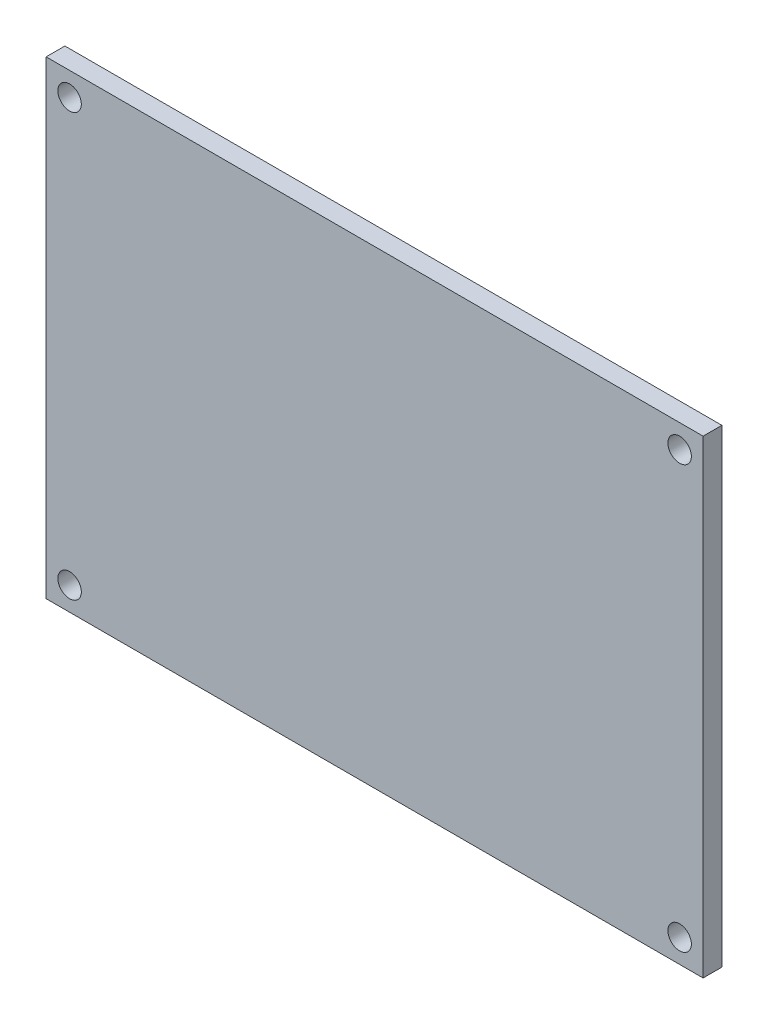
from build123d import *

# Parameters (mm, degrees)
SKETCH1_W           = 142
SKETCH1_H           = 102
SKETCH1_R           = 2.5
BOSS_EXTRUDE1_DEPTH = 4
SKETCH2_W           = 142
SKETCH2_H           = 102
SKETCH2_W_2         = 140
SKETCH2_H_2         = 100
CUT_EXTRUDE1_DEPTH  = 5


with BuildPart() as part:
    # Sketch1 → Boss-Extrude1 (new body)
    with BuildSketch(Plane.XY):
        with Locations((-27.181372549, -6.605392157)):
            Rectangle(SKETCH1_W, SKETCH1_H)
        with Locations((-92.181372549, 38.394607843)):
            Circle(SKETCH1_R, mode=Mode.SUBTRACT)
        with Locations((37.818627451, 38.394607843)):
            Circle(SKETCH1_R, mode=Mode.SUBTRACT)
        with Locations((37.818627451, -51.605392157)):
            Circle(SKETCH1_R, mode=Mode.SUBTRACT)
        with Locations((-92.181372549, -51.605392157)):
            Circle(SKETCH1_R, mode=Mode.SUBTRACT)
    extrude(amount=BOSS_EXTRUDE1_DEPTH)

    # Sketch2 → Cut-Extrude1 (cut, through all)
    with BuildSketch(Plane.XY.offset(4)):
        with Locations((-27.181372549, -6.605392157)):
            Rectangle(SKETCH2_W, SKETCH2_H)
        with Locations((-27.181372549, -6.605392157)):
            Rectangle(SKETCH2_W_2, SKETCH2_H_2, mode=Mode.SUBTRACT)
    extrude(amount=-CUT_EXTRUDE1_DEPTH, mode=Mode.SUBTRACT)


solid = part.part
